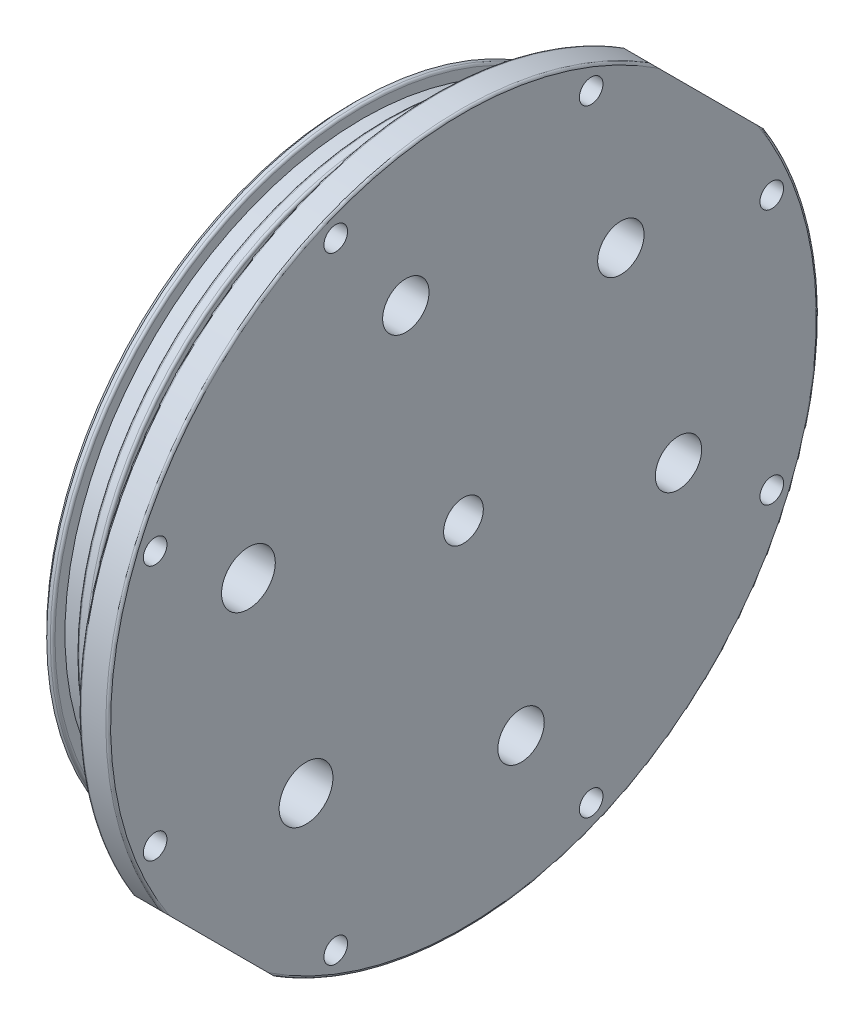
from build123d import *

# Parameters (mm, degrees)
CHAMFER1_SIZE                  = 1.27
FILLET1_R                      = 0.508
F_8_0_199_DIAMETER_HOLE1_D     = 5.0546
F_8_0_199_DIAMETER_HOLE1_DEPTH = 9.149444958
F_8_0_199_DIAMETER_HOLE1_TIP   = 1.518555042
CUT_EXTRUDE1_DEPTH             = 6.35
F_6_32_TAPPED_HOLE1_AT_2_COUNT = 2
F_6_32_TAPPED_HOLE1_AT_2_PITCH = 7.874
M10X1_5_TAPPED_HOLE1_D         = 8.5
M10X1_5_TAPPED_HOLE1_DEPTH     = 27.926342369
M10X1_5_TAPPED_HOLE1_TIP       = 2.553657631
F_7_16_20_TAPPED_HOLE1_D       = 9.92124
F_7_16_20_TAPPED_HOLE1_DEPTH   = 27.499358796
F_7_16_20_TAPPED_HOLE1_TIP     = 2.980641204
F_1_2_20_TAPPED_HOLE1_D        = 11.50874
F_1_2_20_TAPPED_HOLE1_DEPTH    = 25.75242568
F_1_2_20_TAPPED_HOLE1_TIP      = 3.45757432
F_8_32_TAPPED_HOLE1_D          = 3.4544
F_8_32_TAPPED_HOLE1_DEPTH      = 9.721633539
F_8_32_TAPPED_HOLE1_TIP        = 1.037806461


with BuildPart() as part:
    # Sketch1 → Revolve1 (revolve)
    with BuildSketch(Plane.XY):
        Polygon((24.13, -58.42), (24.13, -76), (17.829803922, -76), (17.829803922, -66.421), (17.829803922, -66.294), (15.289803922, -66.294), (15.289803922, -63.65748), (10.184901961, -63.65748), (10.184901961, -66.294), (7.644901961, -66.294), (7.644901961, -63.65748), (2.54, -63.65748), (2.54, -66.294), (0, -66.294), (0, -58.42), (0, 0), (11.43, 0), (24.13, 0), align=None)
    revolve(axis=Axis((24.13, 0, 0), (-1, 0, 0)))

    # Chamfer1
    chamfer1_edges = [part.edges().sort_by_distance(p)[0] for p in [
        (0, 66.294, 0),
    ]]
    chamfer(chamfer1_edges, length=CHAMFER1_SIZE)

    # Fillet1
    fillet1_edges = [part.edges().sort_by_distance(p)[0] for p in [
        (24.13, 76, 0),
        (17.829803922, 76, 0),
        (15.289803922, 66.294, 0),
        (10.184901961, 66.294, 0),
        (7.644901961, 66.294, 0),
        (2.54, 66.294, 0),
    ]]
    fillet(fillet1_edges, radius=FILLET1_R)

    # #8 (0.199) Diameter Hole1
    with Locations(Plane(origin=(24.13, 0, 0), x_dir=(0, 0, -1), z_dir=(1, 0, 0))):
        with Locations((-65.952711024, 27.318507381), (-27.318507381, 65.952711024), (27.318507381, 65.952711024), (65.952711024, 27.318507381), (65.952711024, -27.318507381), (27.318507381, -65.952711024), (-27.318507381, -65.952711024), (-65.952711024, -27.318507381)):
            Hole(F_8_0_199_DIAMETER_HOLE1_D / 2, depth=F_8_0_199_DIAMETER_HOLE1_DEPTH)
            with Locations((0, 0, -(F_8_0_199_DIAMETER_HOLE1_DEPTH + F_8_0_199_DIAMETER_HOLE1_TIP / 2))):  # 118° drill point
                Cone(0, F_8_0_199_DIAMETER_HOLE1_D / 2, F_8_0_199_DIAMETER_HOLE1_TIP, mode=Mode.SUBTRACT)

    # Sketch6 → Cut-Extrude1 (cut)
    with BuildSketch(Plane(origin=(24.13, 0, 0), x_dir=(0, 0, -1), z_dir=(1, 0, 0))):
        with BuildLine():
            Line((40.078453094, 64.573350522), (64.573350522, 40.078453094))
            ThreePointArc((64.573350522, 40.078453094), (53.74011537, 53.74011537), (40.078453094, 64.573350522))
        make_face()
    cut_extrude1 = extrude(amount=-CUT_EXTRUDE1_DEPTH, mode=Mode.SUBTRACT)

    # Sketch9 → #6-32 Tapped Hole1 (revolve, cut)
    with BuildSketch(Plane(origin=(20.979901961, 49.54202241, -55.109781205), x_dir=(0, 0.707106781, 0.707106781), z_dir=(1, 0, 0))):
        Polygon((0, 0), (0, 19.05), (1.35255, 18.23730597), (1.35255, 0), align=None)
    f_6_32_tapped_hole1 = revolve(axis=Axis((20.979901961, 54.032150471, -59.599909266), (0, -0.707106781, 0.707106781)), mode=Mode.SUBTRACT)

    # #6-32 Tapped Hole1 at 2: #6-32 Tapped Hole1 ×2
    with Locations(*[Vector(0, 0.707106781, 0.707106781) * (i * F_6_32_TAPPED_HOLE1_AT_2_PITCH) for i in range(1, F_6_32_TAPPED_HOLE1_AT_2_COUNT)]):
        add(f_6_32_tapped_hole1, mode=Mode.SUBTRACT)

    # Mirror1: #6-32 Tapped Hole1, Cut-Extrude1 across plane
    add(f_6_32_tapped_hole1.mirror(Plane(origin=(0, 0, 0), x_dir=(0, 0.707106781, 0.707106781), z_dir=(0, -0.707106781, 0.707106781))), mode=Mode.SUBTRACT)
    add(cut_extrude1.mirror(Plane(origin=(0, 0, 0), x_dir=(0, 0.707106781, 0.707106781), z_dir=(0, -0.707106781, 0.707106781))), mode=Mode.SUBTRACT)

    # Mirror1 copy 1 sketch → Mirror1 copy 1 (revolve, cut)
    with BuildSketch(Plane(origin=(20.979901961, -49.54202241, 55.109781205), x_dir=(0, 0.707106781, 0.707106781), z_dir=(1, 0, 0))):
        Polygon((0, 0), (0, -19.05), (1.35255, -18.23730597), (1.35255, 0), align=None)
    revolve(axis=Axis((20.979901961, -54.032150471, 59.599909266), (0, -0.707106781, 0.707106781)), mode=Mode.SUBTRACT)

    # M10x1.5 Tapped Hole1
    with Locations(Plane(origin=(24.13, 0, 0), x_dir=(0, 0, -1), z_dir=(1, 0, 0))):
        with Locations((0, 0)):
            Hole(M10X1_5_TAPPED_HOLE1_D / 2, depth=M10X1_5_TAPPED_HOLE1_DEPTH)
            with Locations((0, 0, -(M10X1_5_TAPPED_HOLE1_DEPTH + M10X1_5_TAPPED_HOLE1_TIP / 2))):  # 118° drill point
                Cone(0, M10X1_5_TAPPED_HOLE1_D / 2, M10X1_5_TAPPED_HOLE1_TIP, mode=Mode.SUBTRACT)

    # 7/16-20 Tapped Hole1
    with Locations(Plane(origin=(24.13, 0, 0), x_dir=(0, 0, -1), z_dir=(1, 0, 0))):
        with Locations((12.326257023, -46.002217477), (-12.326257023, 46.002217477), (33.675960454, 33.675960454), (46.002217477, -12.326257023)):
            Hole(F_7_16_20_TAPPED_HOLE1_D / 2, depth=F_7_16_20_TAPPED_HOLE1_DEPTH)
            with Locations((0, 0, -(F_7_16_20_TAPPED_HOLE1_DEPTH + F_7_16_20_TAPPED_HOLE1_TIP / 2))):  # 118° drill point
                Cone(0, F_7_16_20_TAPPED_HOLE1_D / 2, F_7_16_20_TAPPED_HOLE1_TIP, mode=Mode.SUBTRACT)

    # 1/2-20 Tapped Hole1
    with Locations(Plane(origin=(24.13, 0, 0), x_dir=(0, 0, -1), z_dir=(1, 0, 0))):
        with Locations((-46.002217477, 12.326257023), (-33.675960454, -33.675960454)):
            Hole(F_1_2_20_TAPPED_HOLE1_D / 2, depth=F_1_2_20_TAPPED_HOLE1_DEPTH)
            with Locations((0, 0, -(F_1_2_20_TAPPED_HOLE1_DEPTH + F_1_2_20_TAPPED_HOLE1_TIP / 2))):  # 118° drill point
                Cone(0, F_1_2_20_TAPPED_HOLE1_D / 2, F_1_2_20_TAPPED_HOLE1_TIP, mode=Mode.SUBTRACT)

    # #8-32 Tapped Hole1
    with Locations(Plane.ZY):
        with Locations((-9.963187377, 37.183121498), (27.21993412, 27.21993412), (37.183121498, -9.963187377), (9.963187377, -37.183121498), (-27.21993412, -27.21993412), (-37.183121498, 9.963187377)):
            Hole(F_8_32_TAPPED_HOLE1_D / 2, depth=F_8_32_TAPPED_HOLE1_DEPTH)
            with Locations((0, 0, -(F_8_32_TAPPED_HOLE1_DEPTH + F_8_32_TAPPED_HOLE1_TIP / 2))):  # 118° drill point
                Cone(0, F_8_32_TAPPED_HOLE1_D / 2, F_8_32_TAPPED_HOLE1_TIP, mode=Mode.SUBTRACT)


solid = part.part
